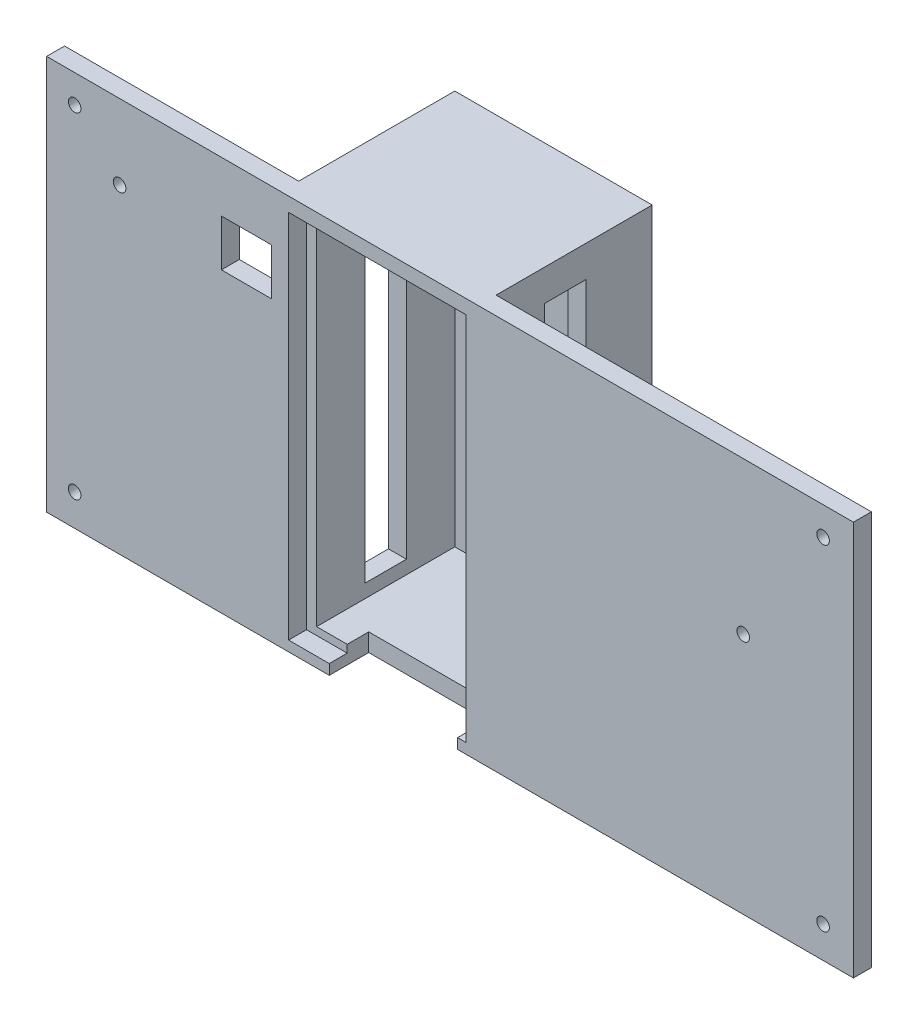
from build123d import *

# Parameters (mm, degrees)
SKETCH1_W                                   = 114.20462943
SKETCH1_H                                   = 55.88
BOSS_EXTRUDE1_DEPTH                         = 2.54
CUT_EXTRUDE2_REACH                          = 13892.916
SKETCH2_W                                   = 7.112
SKETCH2_H                                   = 6.604
SKETCH5_W                                   = 27.94
SKETCH5_H                                   = 55.88
BOSS_EXTRUDE2_DEPTH                         = 19.558
SHELL2_T                                    = -2.54
SKETCH6_W                                   = 25.09706722
SKETCH6_H                                   = 52.434836366
CUT_EXTRUDE3_DEPTH                          = 13891.929495416
SKETCH7_W                                   = 5.85197615
SKETCH7_H                                   = 46.976533267
CUT_EXTRUDE4_DEPTH                          = 13551.404777193
SKETCH8_W                                   = 18.161
SKETCH8_H                                   = 5.588
CUT_EXTRUDE5_DEPTH                          = 19.558
CBORE_FOR_0_BINDING_HEAD_MACHINE_SC_2_COUNT = 2
CBORE_FOR_0_BINDING_HEAD_MACHINE_SC_2_PITCH = 88.953731343
CBORE_FOR_0_BINDING_HEAD_MACHINE_SC_3_COUNT = 2
CBORE_FOR_0_BINDING_HEAD_MACHINE_SC_3_PITCH = 47.42542097
CBORE_FOR_0_BINDING_HEAD_MACHINE_SC_4_COUNT = 2
CBORE_FOR_0_BINDING_HEAD_MACHINE_SC_4_PITCH = 136.214285903
CBORE_FOR_0_BINDING_HEAD_MACHINE_SC_5_COUNT = 2
CBORE_FOR_0_BINDING_HEAD_MACHINE_SC_5_PITCH = 116.073664451
CBORE_FOR_0_BINDING_HEAD_MACHINE_SC_6_COUNT = 2
CBORE_FOR_0_BINDING_HEAD_MACHINE_SC_6_PITCH = 105.943027259
SKETCH16_W                                  = 27.94
SKETCH16_H                                  = 55.88
BOSS_EXTRUDE3_DEPTH                         = 2.54


with BuildPart() as part:
    # Sketch1 → Boss-Extrude1 (new body)
    with BuildSketch(Plane.XY):
        with Locations((3000.394884782, 13522.309097574)):
            Rectangle(SKETCH1_W, SKETCH1_H)
    extrude(amount=-BOSS_EXTRUDE1_DEPTH)

    # Sketch2 → Cut-Extrude2 (cut, up to next)
    with BuildSketch(Plane(origin=(0, 0, -2.54), x_dir=(-1, 0, 0), z_dir=(0, 0, -1)), mode=Mode.PRIVATE) as cut_extrude2_sk1:
        with Locations((-2971.586819557, 13539.747648461)):
            Rectangle(SKETCH2_W, SKETCH2_H)
    cut_extrude2_tool1 = extrude(cut_extrude2_sk1.sketch, amount=-CUT_EXTRUDE2_REACH, mode=Mode.PRIVATE) & part.part
    add(cut_extrude2_tool1.solids().sort_by_distance((2971.58682, 13539.747648, -2.54))[0], mode=Mode.SUBTRACT)

    # Sketch5 → Boss-Extrude2 (add)
    with BuildSketch(Plane(origin=(0, 0, -2.54), x_dir=(-1, 0, 0), z_dir=(0, 0, -1))):
        with Locations((-2990.402009029, 13522.309097574)):
            Rectangle(SKETCH5_W, SKETCH5_H)
    extrude(amount=BOSS_EXTRUDE2_DEPTH)

    # Shell2
    shell2_openings = [part.faces().sort_by_distance(p)[0] for p in [
        (2990.402009029, 13522.309097574, -22.098),
    ]]
    offset(amount=SHELL2_T, openings=shell2_openings, kind=Kind.INTERSECTION)

    # Sketch6 → Cut-Extrude3 (cut, through all)
    with BuildSketch(Plane(origin=(0, 0, -2.54), x_dir=(-1, 0, 0), z_dir=(0, 0, -1))):
        with Locations((-2990.095388415, 13522.03687782)):
            Rectangle(SKETCH6_W, SKETCH6_H)
    extrude(amount=-CUT_EXTRUDE3_DEPTH, mode=Mode.SUBTRACT)

    # Sketch7 → Cut-Extrude4 (cut, through all)
    with BuildSketch(Plane(origin=(3004.372009029, 0, 0), x_dir=(0, 0, -1), z_dir=(1, 0, 0))):
        with Locations((12.319, 13522.309097574)):
            Rectangle(SKETCH7_W, SKETCH7_H)
    extrude(amount=-CUT_EXTRUDE4_DEPTH, mode=Mode.SUBTRACT)

    # Sketch8 → Cut-Extrude5 (cut)
    with BuildSketch(Plane.XZ.offset(-13494.369097574)):
        with Locations((2992.380051535, -2.794)):
            Rectangle(SKETCH8_W, SKETCH8_H)
    extrude(amount=-CUT_EXTRUDE5_DEPTH, mode=Mode.SUBTRACT)

    # Sketch9 → CBORE for _0 Binding Head Machine Screw1 (revolve, cut)
    with BuildSketch(Plane(origin=(3041.896978852, 13528.711016341, -2.54), x_dir=(0, 1, 0), z_dir=(1, 0, 0))):
        Polygon((0, 0), (0, 2.54), (0.889, 2.54), (0.889, 0.8128), (1.98501, 0.8128), (1.98501, 0.635), (2.62001, 0), align=None)
    cbore_for_0_binding_head_machine_screw1 = revolve(axis=Axis((3041.896978852, 13528.711016341, -8.89), (0, 0, 1)), mode=Mode.SUBTRACT)

    # CBORE for _0 Binding Head Machine Sc 2: CBORE for _0 Binding Head Machine Screw1 ×2
    with Locations(*[Vector(-0.992411009873524, 0.12296498477945786, 0) * (i * CBORE_FOR_0_BINDING_HEAD_MACHINE_SC_2_PITCH) for i in range(1, CBORE_FOR_0_BINDING_HEAD_MACHINE_SC_2_COUNT)]):
        add(cbore_for_0_binding_head_machine_screw1, mode=Mode.SUBTRACT)

    # Sketch14 → CBORE for _0 Binding Head Machine Screw2 (revolve, cut)
    with BuildSketch(Plane(origin=(3053.204515133, 13546.256494849, -2.54), x_dir=(0, 1, 0), z_dir=(1, 0, 0))):
        Polygon((0, 0), (0, 2.54), (0.889, 2.54), (0.889, 0.8128), (1.98501, 0.8128), (1.98501, 0.635), (2.62001, 0), align=None)
    cbore_for_0_binding_head_machine_screw2 = revolve(axis=Axis((3053.204515133, 13546.256494849, -8.89), (0, 0, 1)), mode=Mode.SUBTRACT)

    # CBORE for _0 Binding Head Machine Sc 3: CBORE for _0 Binding Head Machine Screw2 ×2
    with Locations(*[(0, -i * CBORE_FOR_0_BINDING_HEAD_MACHINE_SC_3_PITCH, 0) for i in range(1, CBORE_FOR_0_BINDING_HEAD_MACHINE_SC_3_COUNT)]):
        add(cbore_for_0_binding_head_machine_screw2, mode=Mode.SUBTRACT)

    # CBORE for _0 Binding Head Machine Sc 4: CBORE for _0 Binding Head Machine Screw2 ×2
    with Locations(*[Vector(-0.9373151171300654, -0.3484829568278078, 0) * (i * CBORE_FOR_0_BINDING_HEAD_MACHINE_SC_4_PITCH) for i in range(1, CBORE_FOR_0_BINDING_HEAD_MACHINE_SC_4_COUNT)]):
        add(cbore_for_0_binding_head_machine_screw2, mode=Mode.SUBTRACT)

    # CBORE for _0 Binding Head Machine Sc 5: CBORE for _0 Binding Head Machine Screw2 ×2
    with Locations(*[Vector(-0.9127223454224201, -0.4085803717343707, 0) * (i * CBORE_FOR_0_BINDING_HEAD_MACHINE_SC_5_PITCH) for i in range(1, CBORE_FOR_0_BINDING_HEAD_MACHINE_SC_5_COUNT)]):
        add(cbore_for_0_binding_head_machine_screw2, mode=Mode.SUBTRACT)

    # CBORE for _0 Binding Head Machine Sc 6: CBORE for _0 Binding Head Machine Screw2 ×2
    with Locations(*[(-i * CBORE_FOR_0_BINDING_HEAD_MACHINE_SC_6_PITCH, 0, 0) for i in range(1, CBORE_FOR_0_BINDING_HEAD_MACHINE_SC_6_COUNT)]):
        add(cbore_for_0_binding_head_machine_screw2, mode=Mode.SUBTRACT)

    # Sketch16 → Boss-Extrude3 (add)
    with BuildSketch(Plane(origin=(0, 0, -22.098), x_dir=(-1, 0, 0), z_dir=(0, 0, -1))):
        with Locations((-2990.402009029, 13522.309097574)):
            Rectangle(SKETCH16_W, SKETCH16_H)
    extrude(amount=BOSS_EXTRUDE3_DEPTH)


solid = part.part
